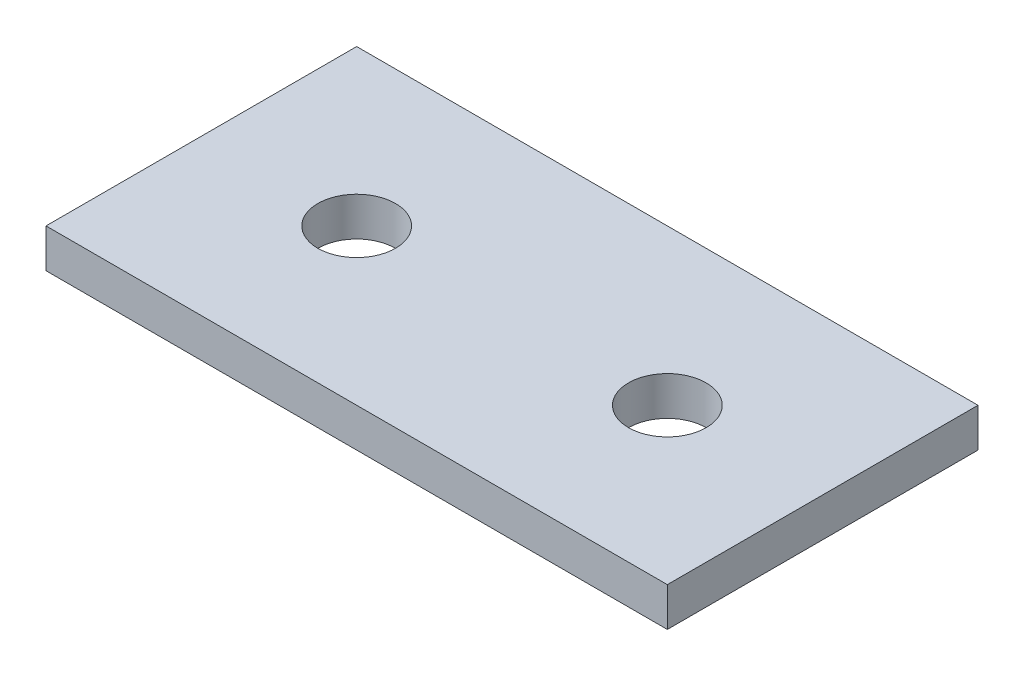
from build123d import *

# Parameters (mm, degrees)
SKETCH1_W           = 50.8
SKETCH1_H           = 25.4
SKETCH1_R           = 3.175
BOSS_EXTRUDE1_DEPTH = 3.175


with BuildPart() as part:
    # Sketch1 → Boss-Extrude1 (new body)
    with BuildSketch(Plane(origin=(0, 0, 0), x_dir=(1, 0, 0), z_dir=(0, 1, 0))):
        with Locations((25.4, 12.7)):
            Rectangle(SKETCH1_W, SKETCH1_H)
        with Locations((12.7, 12.7)):
            Circle(SKETCH1_R, mode=Mode.SUBTRACT)
        with Locations((38.1, 12.7)):
            Circle(SKETCH1_R, mode=Mode.SUBTRACT)
    extrude(amount=BOSS_EXTRUDE1_DEPTH)


solid = part.part
